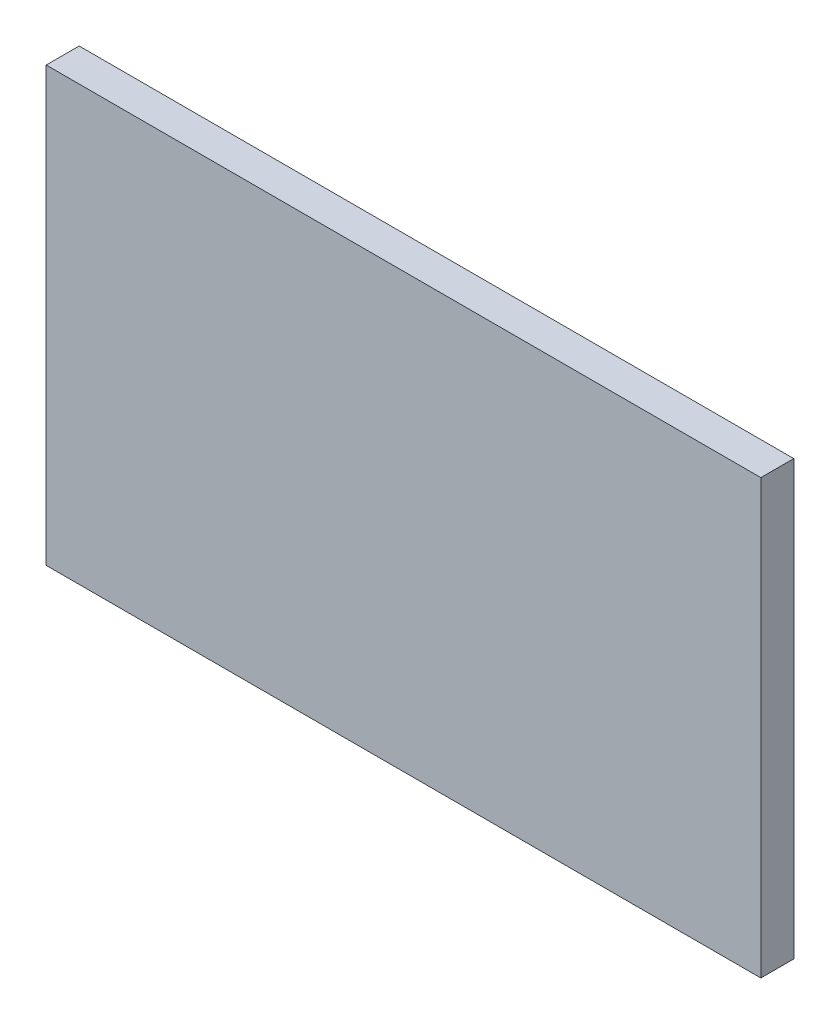
from build123d import *

# Parameters (mm, degrees)
ESQUISSE1_W        = 164.9
ESQUISSE1_H        = 100
BOSS_EXTRU_1_DEPTH = 7.6


with BuildPart() as part:
    # Esquisse1 → Boss.-Extru.1 (new body)
    with BuildSketch(Plane.XY):
        with Locations((82.45, 50)):
            Rectangle(ESQUISSE1_W, ESQUISSE1_H)
    extrude(amount=BOSS_EXTRU_1_DEPTH)


solid = part.part
